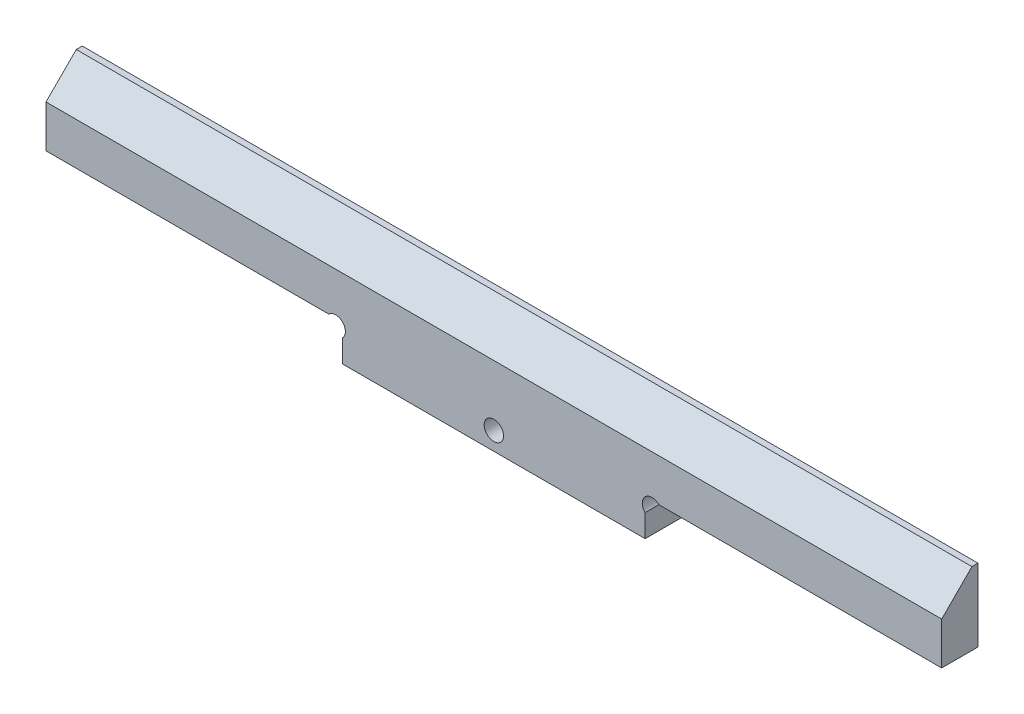
from build123d import *

# Parameters (mm, degrees)
ESQUISSE1_R             = 1.6
BOSS_EXTRU_1_DEPTH      = 6
ENL_V_MAT_EXTRU_1_DEPTH = 149


with BuildPart() as part:
    # Esquisse1 → Boss.-Extru.1 (new body)
    with BuildSketch(Plane.XY):
        with BuildLine():
            Line((49, 3.7372583), (49, 0))
            Line((49, 0), (99, 0))
            Line((99, 0), (99, 3.7372583))
            ThreePointArc((99, 3.7372583), (99, 6), (101.2627417, 6))
            Line((101.2627417, 6), (148, 6))
            Line((148, 6), (148, 18))
            Line((148, 18), (0, 18))
            Line((0, 18), (0, 6))
            Line((0, 6), (46.7372583, 6))
            ThreePointArc((46.7372583, 6), (49, 6), (49, 3.7372583))
        make_face()
        with Locations((74, 3)):
            Circle(ESQUISSE1_R, mode=Mode.SUBTRACT)
    extrude(amount=BOSS_EXTRU_1_DEPTH)

    # Esquisse2 → Enlèv. mat.-Extru.1 (cut, through all)
    with BuildSketch(Plane.ZY):
        Polygon((1, 18), (6, 13), (6, 18), align=None)
    extrude(amount=-ENL_V_MAT_EXTRU_1_DEPTH, mode=Mode.SUBTRACT)


solid = part.part
